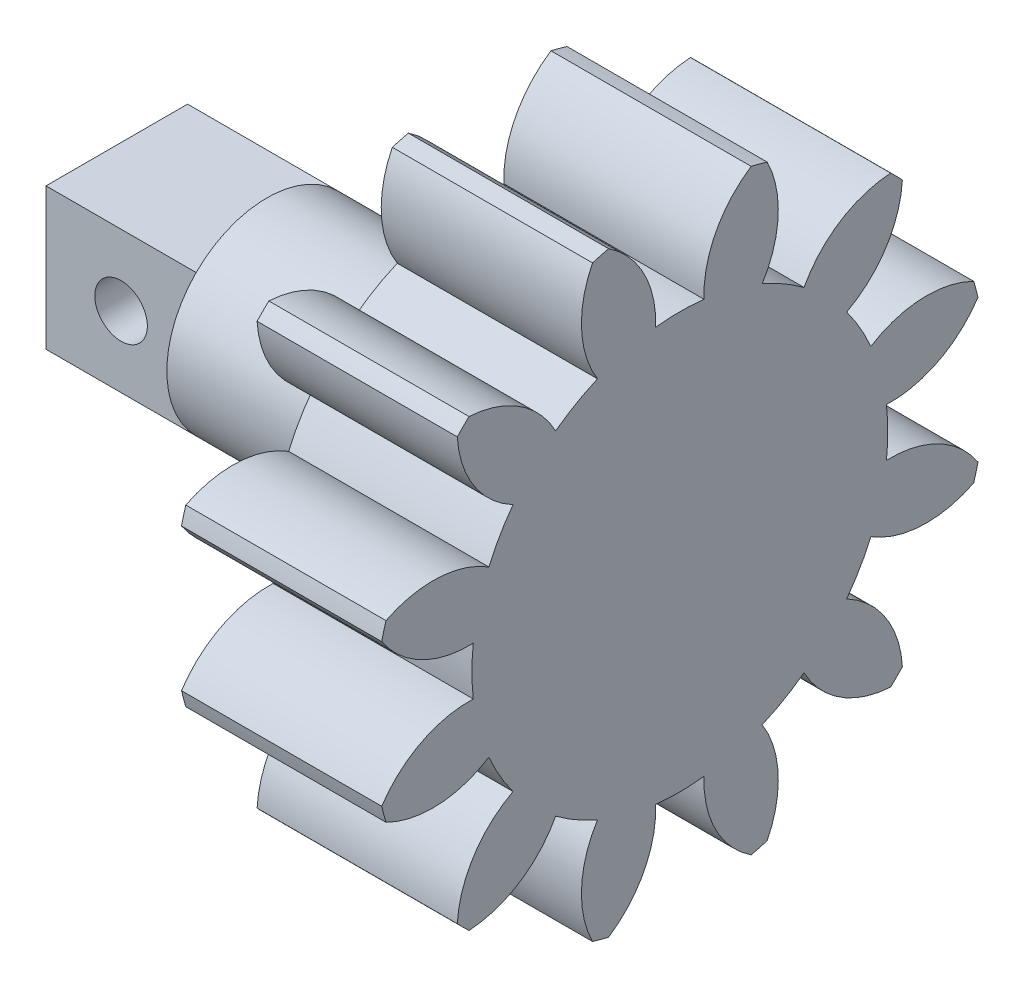
from build123d import *

# Parameters (mm, degrees)
BASPROSKE_W             = 10
BASPROSKE_H             = 12.25
TOOTHCUT_DEPTH          = 21.003124756
TEETHCUTS_COUNT         = 12
TEETHCUTS_ANGLE         = 330
BORSKE_R                = 4.5
BORE_DEPTH              = 50.0000508
ESQUISSE4_R             = 16.84973796
ENL_V_MAT_EXTRU_2_DEPTH = 2
ESQUISSE5_R             = 5.070841349
BOSS_EXTRU_7_DEPTH      = 8
ESQUISSE6_R             = 4
BOSS_EXTRU_8_DEPTH      = 8.5
ESQUISSE7_W             = 5.65685425
ESQUISSE7_H             = 5.65685425
BOSS_EXTRU_9_DEPTH      = 6
ESQUISSE8_R             = 1.05
ENL_V_MAT_EXTRU_3_DEPTH = 6


with BuildPart() as part:
    # BasProSke → Base-Revolve (revolve)
    with BuildSketch(Plane(origin=(0, 0, 0), x_dir=(1, 0, 0), z_dir=(0, 1, 0)), mode=Mode.PRIVATE) as base_revolve_sk:
        with Locations((5, 6.125)):
            Rectangle(BASPROSKE_W, BASPROSKE_H)
    revolve(base_revolve_sk.sketch.rotate(Axis((-10, 0, 0), (1, 0, 0)), 180), axis=Axis((-10, 0, 0), (1, 0, 0)))

    # TooCutSke → ToothCut (cut, through all)
    with BuildSketch(Plane(origin=(0, 0, 0), x_dir=(0, 0, -1), z_dir=(1, 0, 0))):
        with BuildLine():
            ThreePointArc((0.965128363, 8.255274647), (0, 8.3115), (-0.965128363, 8.255274647))
            ThreePointArc((-0.965128363, 8.255274647), (-1.43628674, 10.346733197), (-2.878284339, 11.933185846))
            ThreePointArc((-2.878284339, 11.933185846), (0, 12.2754), (2.878284339, 11.933185846))
            ThreePointArc((2.878284339, 11.933185846), (1.43628674, 10.346733197), (0.965128363, 8.255274647))
        make_face()
    toothcut = extrude(amount=TOOTHCUT_DEPTH, mode=Mode.SUBTRACT)

    # TeethCuts: ToothCut ×12 about axis
    teethcuts_axis = Axis((-10, 0, 0), (1, 0, 0))
    for i in range(1, TEETHCUTS_COUNT):
        add(toothcut.rotate(teethcuts_axis, i * TEETHCUTS_ANGLE / (TEETHCUTS_COUNT - 1)), mode=Mode.SUBTRACT)

    # BorSke → Bore (cut, symmetric)
    with BuildSketch(Plane(origin=(0, 0, 0), x_dir=(0, 0, -1), z_dir=(1, 0, 0))):
        with Locations(Location((0, 0, 0), (0, 0, 180))):
            Circle(BORSKE_R)
    extrude(amount=BORE_DEPTH, both=True, mode=Mode.SUBTRACT)

    # Esquisse4 → Enlèv. mat.-Extru.2 (cut)
    with BuildSketch(Plane.ZY):
        Circle(ESQUISSE4_R)
    extrude(amount=-ENL_V_MAT_EXTRU_2_DEPTH, mode=Mode.SUBTRACT)

    # Esquisse5 → Boss.-Extru.7 (add)
    with BuildSketch(Plane.ZY.offset(-2)):
        Circle(ESQUISSE5_R)
    extrude(amount=-BOSS_EXTRU_7_DEPTH)

    # Esquisse6 → Boss.-Extru.8 (add)
    with BuildSketch(Plane.ZY.offset(-2)):
        Circle(ESQUISSE6_R)
    extrude(amount=BOSS_EXTRU_8_DEPTH)

    # Esquisse7 → Boss.-Extru.9 (add)
    with BuildSketch(Plane.ZY.offset(6.5)):
        Rectangle(ESQUISSE7_W, ESQUISSE7_H)
    extrude(amount=BOSS_EXTRU_9_DEPTH)

    # Esquisse8 → Enlèv. mat.-Extru.3 (cut)
    with BuildSketch(Plane(origin=(0, 0, -2.828427125), x_dir=(-1, 0, 0), z_dir=(0, 0, -1))):
        with Locations((9.5, 0)):
            Circle(ESQUISSE8_R)
    extrude(amount=-ENL_V_MAT_EXTRU_3_DEPTH, mode=Mode.SUBTRACT)


solid = part.part
